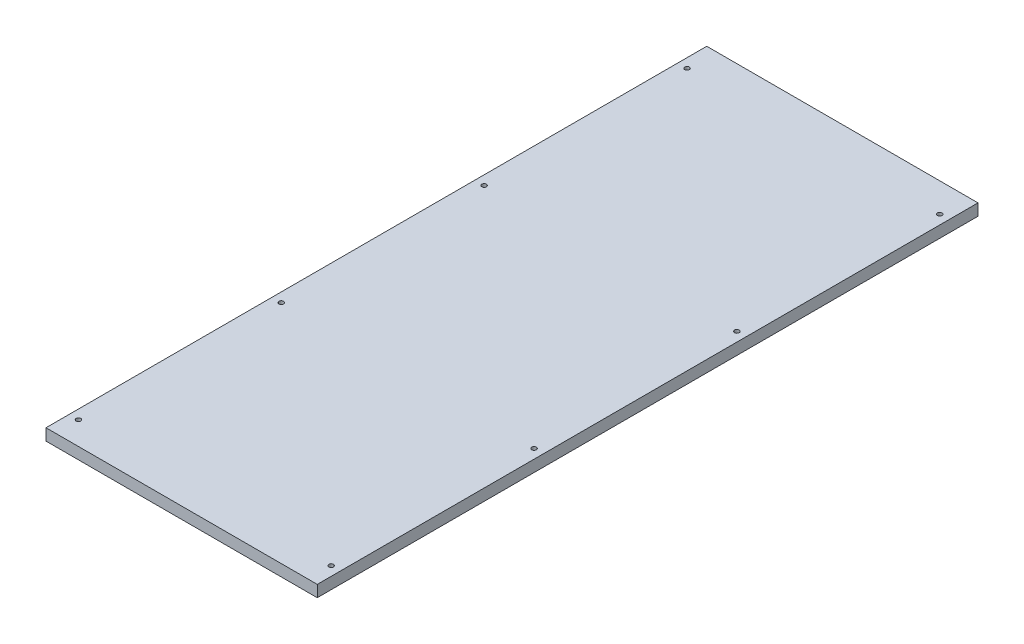
from build123d import *

# Parameters (mm, degrees)
SKETCH1_W           = 234
SKETCH1_H           = 570
SKETCH1_R           = 2
BOSS_EXTRUDE1_DEPTH = 10


with BuildPart() as part:
    # Sketch1 → Boss-Extrude1 (new body)
    with BuildSketch(Plane(origin=(0, 0, 0), x_dir=(1, 0, 0), z_dir=(0, 1, 0))):
        Rectangle(SKETCH1_W, SKETCH1_H)
        with Locations((109, 260)):
            Circle(SKETCH1_R, mode=Mode.SUBTRACT)
        with Locations((109, 85)):
            Circle(SKETCH1_R, mode=Mode.SUBTRACT)
        with Locations((109, -90)):
            Circle(SKETCH1_R, mode=Mode.SUBTRACT)
        with Locations((109, -265)):
            Circle(SKETCH1_R, mode=Mode.SUBTRACT)
        with Locations((-109, -265)):
            Circle(SKETCH1_R, mode=Mode.SUBTRACT)
        with Locations((-109, -90)):
            Circle(SKETCH1_R, mode=Mode.SUBTRACT)
        with Locations((-109, 85)):
            Circle(SKETCH1_R, mode=Mode.SUBTRACT)
        with Locations((-109, 260)):
            Circle(SKETCH1_R, mode=Mode.SUBTRACT)
    extrude(amount=BOSS_EXTRUDE1_DEPTH)


solid = part.part
